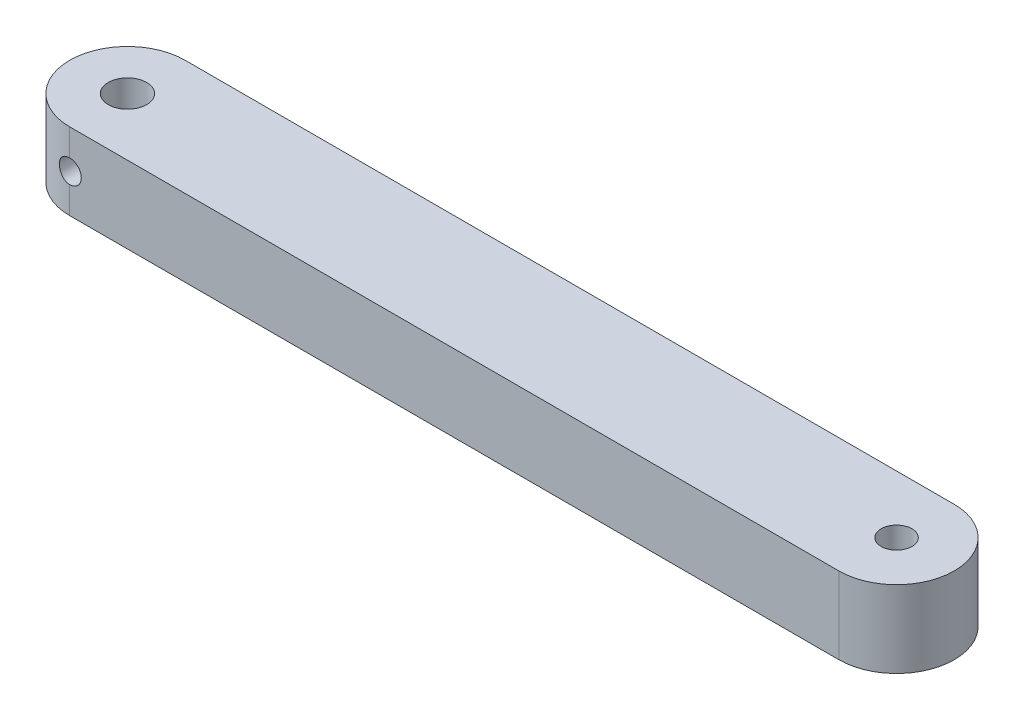
from build123d import *

# Parameters (mm, degrees)
SKETCH2_R           = 2.5
SKETCH2_R_2         = 2
BOSS_EXTRUDE1_DEPTH = 10
SKETCH4_R           = 1.5
CUT_EXTRUDE3_DEPTH  = 110.001146783


with BuildPart() as part:
    # Sketch2 → Boss-Extrude1 (new body)
    with BuildSketch(Plane(origin=(0, 0, 0), x_dir=(1, 0, 0), z_dir=(0, 1, 0))):
        with BuildLine():
            Line((0, 7.5), (100, 7.5))
            ThreePointArc((100, 7.5), (107.5, 0), (100, -7.5))
            Line((100, -7.5), (0, -7.5))
            ThreePointArc((0, -7.5), (-7.5, 0), (0, 7.5))
        make_face()
        Circle(SKETCH2_R, mode=Mode.SUBTRACT)
        with Locations((100, 0)):
            Circle(SKETCH2_R_2, mode=Mode.SUBTRACT)
    extrude(amount=BOSS_EXTRUDE1_DEPTH)

    # Sketch4 → Cut-Extrude3 (cut, through all)
    with BuildSketch(Plane(origin=(0, 0, -7.5), x_dir=(-1, 0, 0), z_dir=(0, 0, -1))):
        with Locations((0, 5)):
            Circle(SKETCH4_R)
    extrude(amount=-CUT_EXTRUDE3_DEPTH, mode=Mode.SUBTRACT)


solid = part.part
